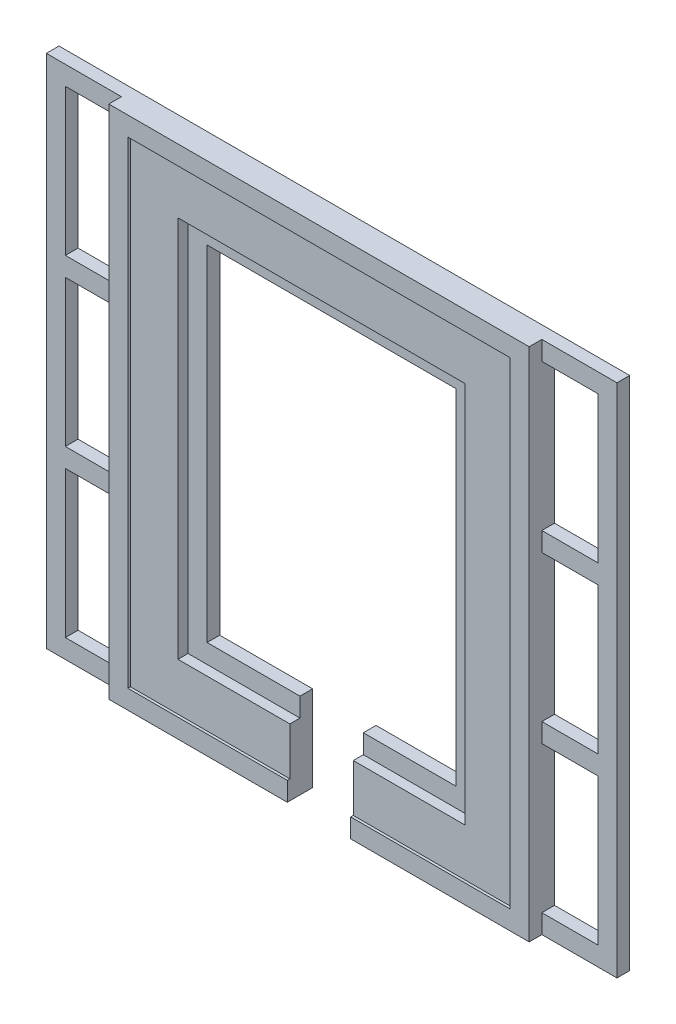
from build123d import *

# Parameters (mm, degrees)
SKETCH1_W           = 8.85
SKETCH1_H           = 23.1
BOSS_EXTRUDE1_DEPTH = 2
BOSS_EXTRUDE2_DEPTH = 3.59
BOSS_EXTRUDE3_DEPTH = 4


with BuildPart() as part:
    # Sketch1 → Boss-Extrude1 (new body)
    with BuildSketch(Plane.XY):
        Polygon((0, 81.3), (0, 0), (40, 0), (40, 13.5), (25.35, 13.5), (25.35, 67.8), (64.65, 67.8), (64.65, 13.5), (50, 13.5), (50, 0), (90, 0), (90, 81.3), align=None)
        with Locations((7.425, 66.75)):
            Rectangle(SKETCH1_W, SKETCH1_H, mode=Mode.SUBTRACT)
        with Locations((7.425, 40.65)):
            Rectangle(SKETCH1_W, SKETCH1_H, mode=Mode.SUBTRACT)
        with Locations((7.425, 14.55)):
            Rectangle(SKETCH1_W, SKETCH1_H, mode=Mode.SUBTRACT)
        with Locations((82.575, 66.75)):
            Rectangle(SKETCH1_W, SKETCH1_H, mode=Mode.SUBTRACT)
        with Locations((82.575, 40.65)):
            Rectangle(SKETCH1_W, SKETCH1_H, mode=Mode.SUBTRACT)
        with Locations((82.575, 14.55)):
            Rectangle(SKETCH1_W, SKETCH1_H, mode=Mode.SUBTRACT)
    extrude(amount=BOSS_EXTRUDE1_DEPTH)

    # Sketch1_3 → Boss-Extrude2 (add)
    with BuildSketch(Plane.XY):
        Polygon((14.85, 3), (40, 3), (40, 10.5), (22.35, 10.5), (22.35, 70.8), (67.65, 70.8), (67.65, 10.5), (50, 10.5), (50, 3), (75.15, 3), (75.15, 78.3), (14.85, 78.3), align=None)
    extrude(amount=BOSS_EXTRUDE2_DEPTH)

    # Sketch1_4 → Boss-Extrude3 (add)
    with BuildSketch(Plane.XY):
        Polygon((11.85, 3), (11.85, 0), (40, 0), (40, 3), (14.85, 3), (14.85, 78.3), (75.15, 78.3), (75.15, 3), (50, 3), (50, 0), (78.15, 0), (78.15, 3), (78.15, 26.1), (78.15, 29.1), (78.15, 52.2), (78.15, 55.2), (78.15, 78.3), (78.15, 81.3), (11.85, 81.3), (11.85, 78.3), (11.85, 55.2), (11.85, 52.2), (11.85, 29.1), (11.85, 26.1), align=None)
    extrude(amount=BOSS_EXTRUDE3_DEPTH)


solid = part.part
